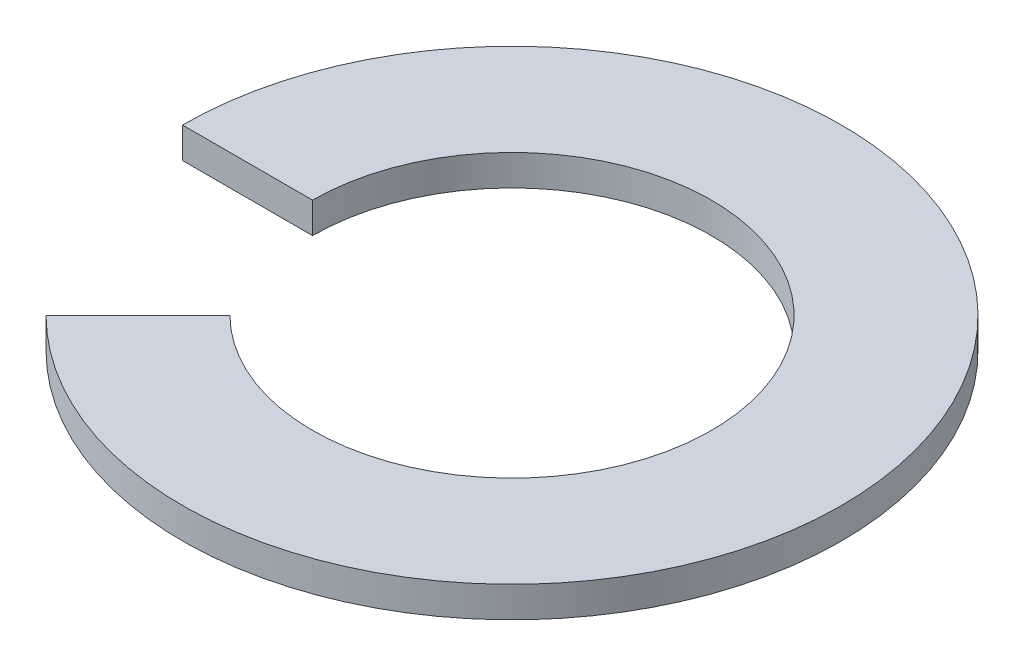
from build123d import *

# Parameters (mm, degrees)
BOSS_EXTRUDE1_DEPTH = 1.5


with BuildPart() as part:
    # Sketch1 → Boss-Extrude1 (new body)
    with BuildSketch(Plane(origin=(0, 0, 0), x_dir=(1, 0, 0), z_dir=(0, 1, 0))):
        with BuildLine():
            Line((-16.0655, 0), (-9.725, 0))
            ThreePointArc((-9.725, 0), (8.984728454, 3.72159638), (-6.876613447, -6.876613447))
            Line((-6.876613447, -6.876613447), (-11.360023993, -11.360023993))
            ThreePointArc((-11.360023993, -11.360023993), (14.84258663, 6.148000683), (-16.0655, 0))
        make_face()
    extrude(amount=BOSS_EXTRUDE1_DEPTH)


solid = part.part
